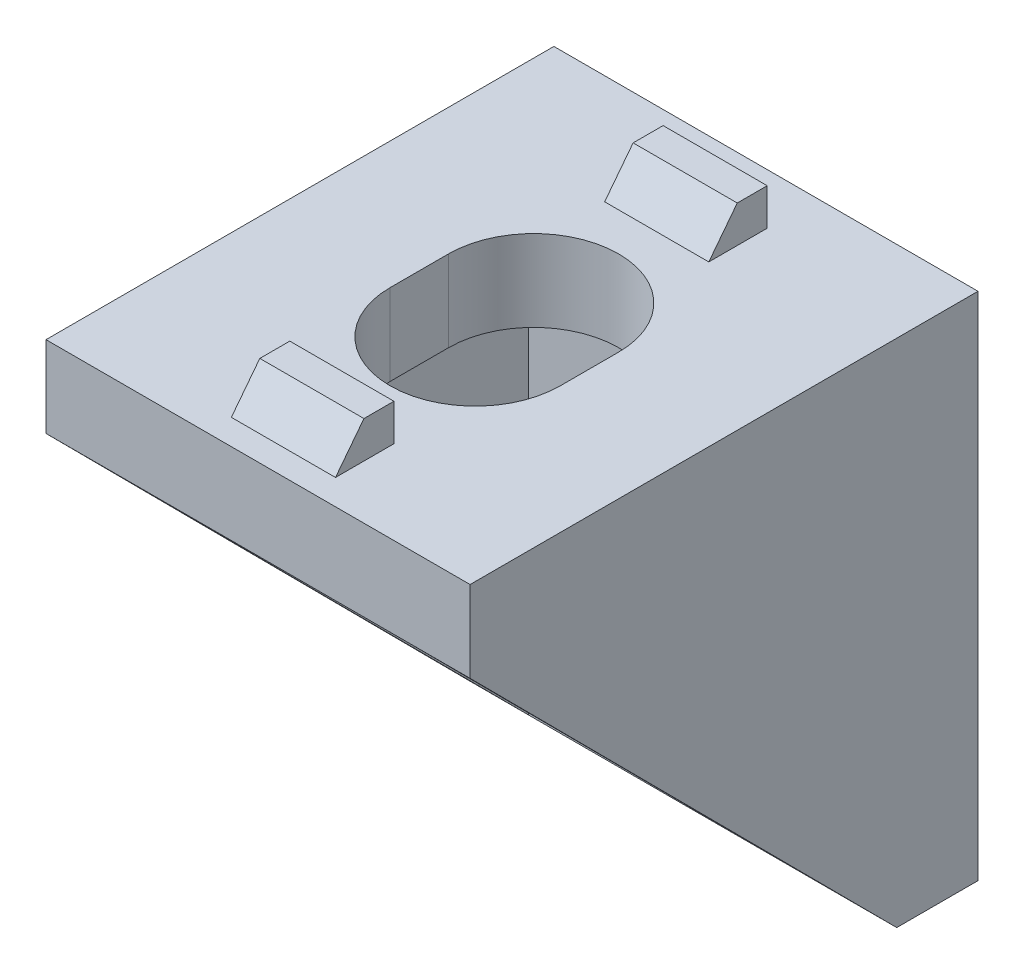
from build123d import *

# Parameters (mm, degrees)
CROQUIS1_W               = 16.7
CROQUIS1_H               = 20.1
SALIENTE_EXTRUIR1_DEPTH  = 3.2
CROQUIS2_W               = 20
CROQUIS2_H               = 3.2
SALIENTE_EXTRUIR2_DEPTH  = 16.7
SALIENTE_EXTRUIR3_DEPTH  = 2.2
SALIENTE_EXTRUIR4_DEPTH  = 2.2
CROQUIS5_W               = 6.7
CROQUIS5_H               = 2.4
CORTAR_EXTRUIR1_DEPTH    = 3.2
CROQUIS6_W               = 6.7
CROQUIS6_H               = 2.3
CORTAR_EXTRUIR2_DEPTH    = 3.2
CROQUIS7_W               = 4.1
CROQUIS7_H               = 1.18
SALIENTE_EXTRUIR9_DEPTH  = 1.45
SALIENTE_EXTRUIR10_DEPTH = 4.1
CROQUIS10_W              = 4.098890586
CROQUIS10_H              = 1.18
SALIENTE_EXTRUIR13_DEPTH = 1.45
SALIENTE_EXTRUIR14_DEPTH = 4.1
SALIENTE_EXTRUIR16_DEPTH = 4.1


with BuildPart() as part:
    # Croquis1 → Saliente-Extruir1 (new body)
    with BuildSketch(Plane.XY):
        Rectangle(CROQUIS1_W, CROQUIS1_H)
    extrude(amount=SALIENTE_EXTRUIR1_DEPTH)

    # Croquis2 → Saliente-Extruir2 (add)
    with BuildSketch(Plane.ZY.offset(8.35)):
        with Locations((10, 8.45)):
            Rectangle(CROQUIS2_W, CROQUIS2_H)
    extrude(amount=-SALIENTE_EXTRUIR2_DEPTH)

    # Croquis3 → Saliente-Extruir3 (add)
    with BuildSketch(Plane.ZY.offset(8.35)):
        Polygon((20, 6.85), (3.2, -10.05), (3.2, 6.85), align=None)
    extrude(amount=-SALIENTE_EXTRUIR3_DEPTH)

    # Croquis4 → Saliente-Extruir4 (add)
    with BuildSketch(Plane(origin=(8.35, 0, 0), x_dir=(0, 0, -1), z_dir=(1, 0, 0))):
        Polygon((-20, 6.85), (-3.2, -10.05), (-3.2, 6.85), align=None)
    extrude(amount=-SALIENTE_EXTRUIR4_DEPTH)

    # Croquis5 → Cortar-Extruir1 (cut)
    with BuildSketch(Plane(origin=(0, 0, 0), x_dir=(-1, 0, 0), z_dir=(0, 0, -1))):
        with BuildLine():
            ThreePointArc((-3.35, 1.5), (0, 4.85), (3.35, 1.5))
            Line((3.35, 1.5), (-3.35, 1.5))
        make_face()
        with Locations((0, 0.3)):
            Rectangle(CROQUIS5_W, CROQUIS5_H)
        with BuildLine():
            Line((3.35, -0.9), (-3.35, -0.9))
            ThreePointArc((-3.35, -0.9), (0, -4.25), (3.35, -0.9))
        make_face()
    extrude(amount=-CORTAR_EXTRUIR1_DEPTH, mode=Mode.SUBTRACT)

    # Croquis6 → Cortar-Extruir2 (cut)
    with BuildSketch(Plane(origin=(0, 10.05, 0), x_dir=(1, 0, 0), z_dir=(0, 1, 0))):
        with BuildLine():
            ThreePointArc((-3.35, -9.15), (0, -5.8), (3.35, -9.15))
            Line((3.35, -9.15), (-3.35, -9.15))
        make_face()
        with Locations((0, -10.3)):
            Rectangle(CROQUIS6_W, CROQUIS6_H)
        with BuildLine():
            Line((3.35, -11.45), (-3.35, -11.45))
            ThreePointArc((-3.35, -11.45), (0, -14.8), (3.35, -11.45))
        make_face()
    extrude(amount=-CORTAR_EXTRUIR2_DEPTH, mode=Mode.SUBTRACT)

    # Croquis7 → Saliente-Extruir9 (add)
    with BuildSketch(Plane(origin=(0, 0, 0), x_dir=(-1, 0, 0), z_dir=(0, 0, -1))):
        with Locations((0, 7.46)):
            Rectangle(CROQUIS7_W, CROQUIS7_H)
        with Locations((0, -7.34)):
            Rectangle(CROQUIS7_W, CROQUIS7_H)
    extrude(amount=SALIENTE_EXTRUIR9_DEPTH)

    # Croquis9 → Saliente-Extruir10 (add)
    with BuildSketch(Plane.ZY.offset(2.05)):
        Polygon((-1.45, 6.87), (0, 5.75), (0, 6.87), align=None)
        Polygon((-1.45, -7.93), (0, -9.05), (0, -7.93), align=None)
    extrude(amount=-SALIENTE_EXTRUIR10_DEPTH)

    # Croquis10 → Saliente-Extruir13 (add)
    with BuildSketch(Plane(origin=(0, 10.05, 0), x_dir=(1, 0, 0), z_dir=(0, 1, 0))):
        with Locations((-0.000554707, -2.59)):
            Rectangle(CROQUIS10_W, CROQUIS10_H)
        with Locations((-0.000554707, -17.29)):
            Rectangle(CROQUIS10_W, CROQUIS10_H)
    extrude(amount=SALIENTE_EXTRUIR13_DEPTH)

    # Croquis12 → Saliente-Extruir14 (add)
    with BuildSketch(Plane(origin=(2.048890586, 0, 0), x_dir=(0, 0, -1), z_dir=(1, 0, 0))):
        Polygon((-17.88, 11.5), (-19, 10.05), (-17.88, 10.05), align=None)
        Polygon((-3.18, 11.5), (-4.3, 10.05), (-3.18, 10.05), align=None)
    extrude(amount=-SALIENTE_EXTRUIR14_DEPTH)

    # Croquis13 → Saliente-Extruir16 (add)
    with BuildSketch(Plane.ZY.offset(2.05)):
        Polygon((2, 11.5), (2, 10.05), (4.3, 10.05), (3.18, 11.5), align=None)
        Polygon((16.7, 11.5), (16.7, 10.05), (19, 10.05), (17.88, 11.5), align=None)
    extrude(amount=-SALIENTE_EXTRUIR16_DEPTH)


solid = part.part
